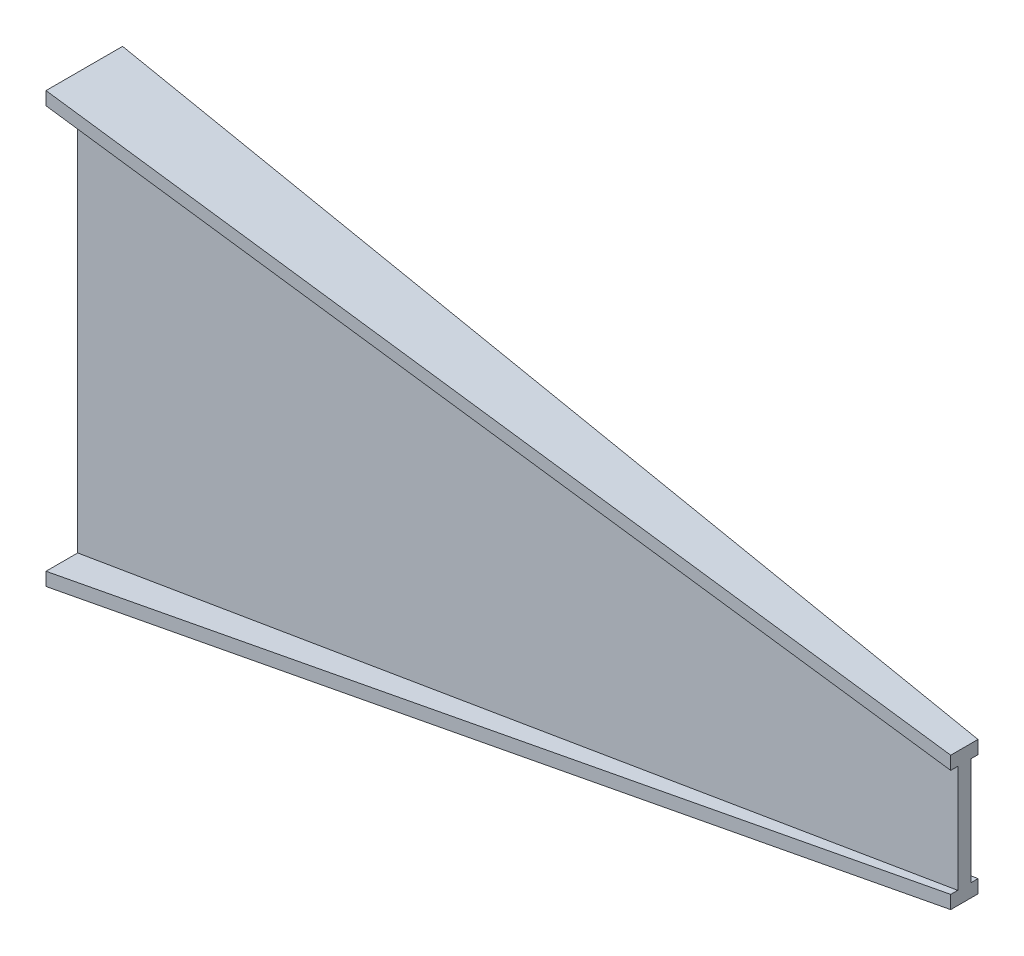
from build123d import *


with BuildPart() as part:
    # Sketch1 → Loft l4 section 0
    with BuildSketch(Plane(origin=(0, 0, 0), x_dir=(0, 0, -1), z_dir=(1, 0, 0))):
        Polygon((-51, 244), (36, 244), (36, 229), (0, 229), (0, -229), (36, -229), (36, -244), (-51, -244), (-51, -229), (-15, -229), (-15, 229), (-51, 229), align=None)
    # Sketch4 → Loft l4 section 1
    with BuildSketch(Plane(origin=(1000, 0, -1000), x_dir=(0, 0, 1), z_dir=(-1, 0, 0))):
        Polygon((992, 76), (1023, 76), (1023, 61), (1015, 61), (1015, -61), (1023, -61), (1023, -76), (992, -76), (992, -61), (1000, -61), (1000, 61), (992, 61), align=None)
    loft()


solid = part.part
